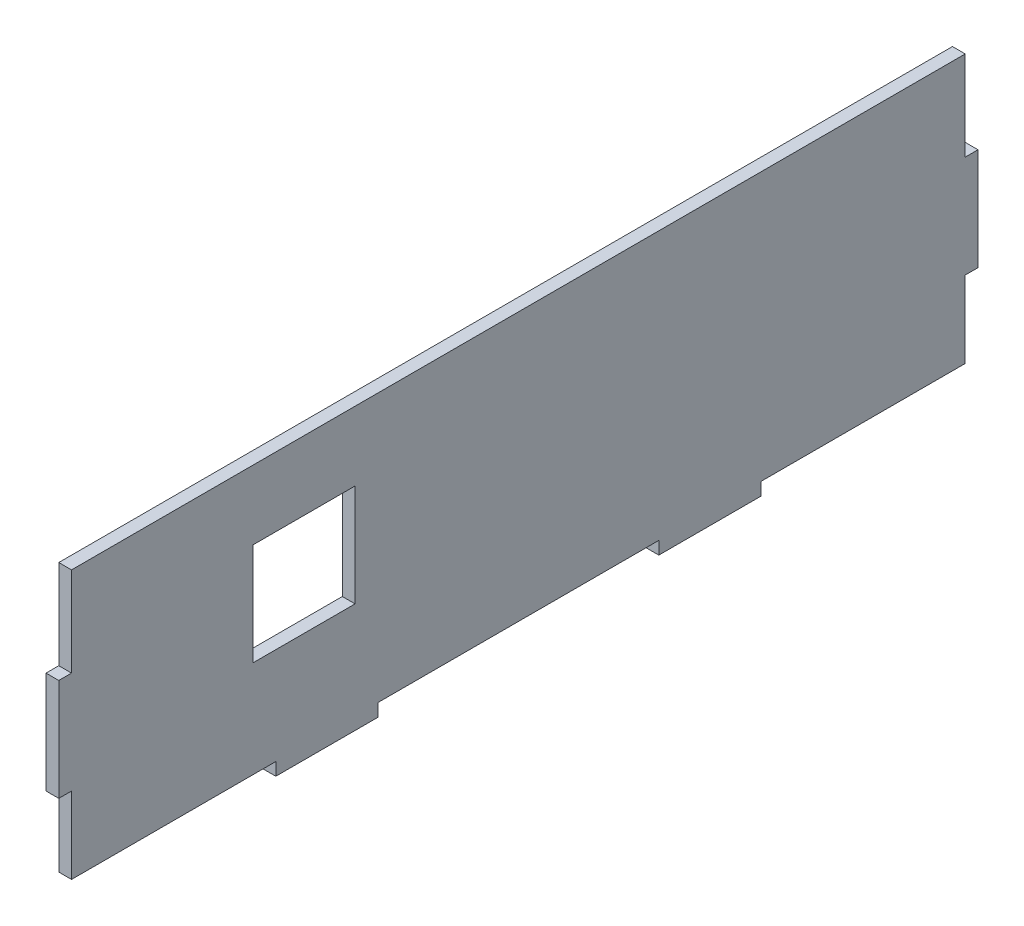
from build123d import *

# Parameters (mm, degrees)
BOSS_EXTRUDE1_DEPTH = 3.175
SKETCH2_W           = 222.25
SKETCH2_H           = 3.175
CUT_EXTRUDE1_DEPTH  = 4.175
SKETCH3_W           = 25.4
SKETCH3_H           = 25.4
CUT_EXTRUDE2_DEPTH  = 10


with BuildPart() as part:
    # Sketch1 → Boss-Extrude1 (new body)
    with BuildSketch(Plane(origin=(0, 0, 0), x_dir=(0, 0, -1), z_dir=(1, 0, 0))):
        Polygon((-116.659983875, 27.078998721), (-116.659983875, 1.678998721), (-119.834983875, 1.678998721), (-119.834983875, -23.721001279), (-116.659983875, -23.721001279), (-116.659983875, -42.771001279), (-65.859983875, -42.771001279), (-65.859983875, -45.946001279), (-40.459983875, -45.946001279), (-40.459983875, -42.771001279), (29.390016125, -42.771001279), (29.390016125, -45.946001279), (54.790016125, -45.946001279), (54.790016125, -42.771001279), (105.590016125, -42.771001279), (105.590016125, -23.721001279), (108.765016125, -23.721001279), (108.765016125, 1.678998721), (105.590016125, 1.678998721), (105.590016125, 27.078998721), align=None)
    extrude(amount=BOSS_EXTRUDE1_DEPTH)

    # Sketch2 → Cut-Extrude1 (cut, through all)
    with BuildSketch(Plane(origin=(3.175, 0, 0), x_dir=(0, 0, -1), z_dir=(1, 0, 0))):
        with Locations((-5.534983875, 25.491498721)):
            Rectangle(SKETCH2_W, SKETCH2_H)
    extrude(amount=-CUT_EXTRUDE1_DEPTH, mode=Mode.SUBTRACT)

    # Sketch3 → Cut-Extrude2 (cut)
    with BuildSketch(Plane.ZY):
        with Locations((58.843980592, -5.975859027)):
            Rectangle(SKETCH3_W, SKETCH3_H)
    extrude(amount=-CUT_EXTRUDE2_DEPTH, mode=Mode.SUBTRACT)


solid = part.part
